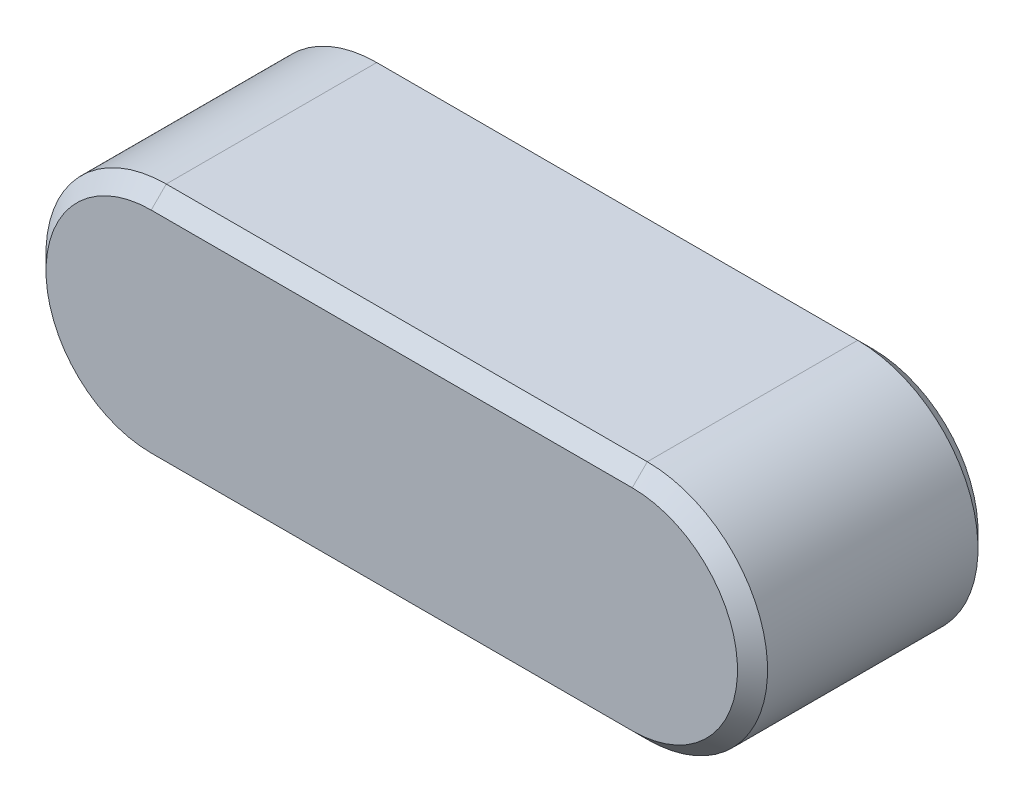
from build123d import *

# Parameters (mm, degrees)
BASEKEY_DEPTH = 2
CHAMFER1_SIZE = 0.25


with BuildPart() as part:
    # Sketch1 → BaseKey (new body, symmetric)
    with BuildSketch(Plane.XY):
        with BuildLine():
            Line((-8, 2), (0, 2))
            ThreePointArc((0, 2), (2, 0), (0, -2))
            Line((0, -2), (-8, -2))
            ThreePointArc((-8, -2), (-10, 0), (-8, 2))
        make_face()
    extrude(amount=BASEKEY_DEPTH, both=True)

    # Chamfer1
    chamfer1_edges = [part.edges().sort_by_distance(p)[0] for p in [
        (2, 0, 2),
        (-4, 2, 2),
        (-10, 0, 2),
        (-4, 2, -2),
        (2, 0, -2),
        (-4, -2, -2),
        (-10, 0, -2),
        (-4, -2, 2),
    ]]
    chamfer(chamfer1_edges, length=CHAMFER1_SIZE)


solid = part.part
